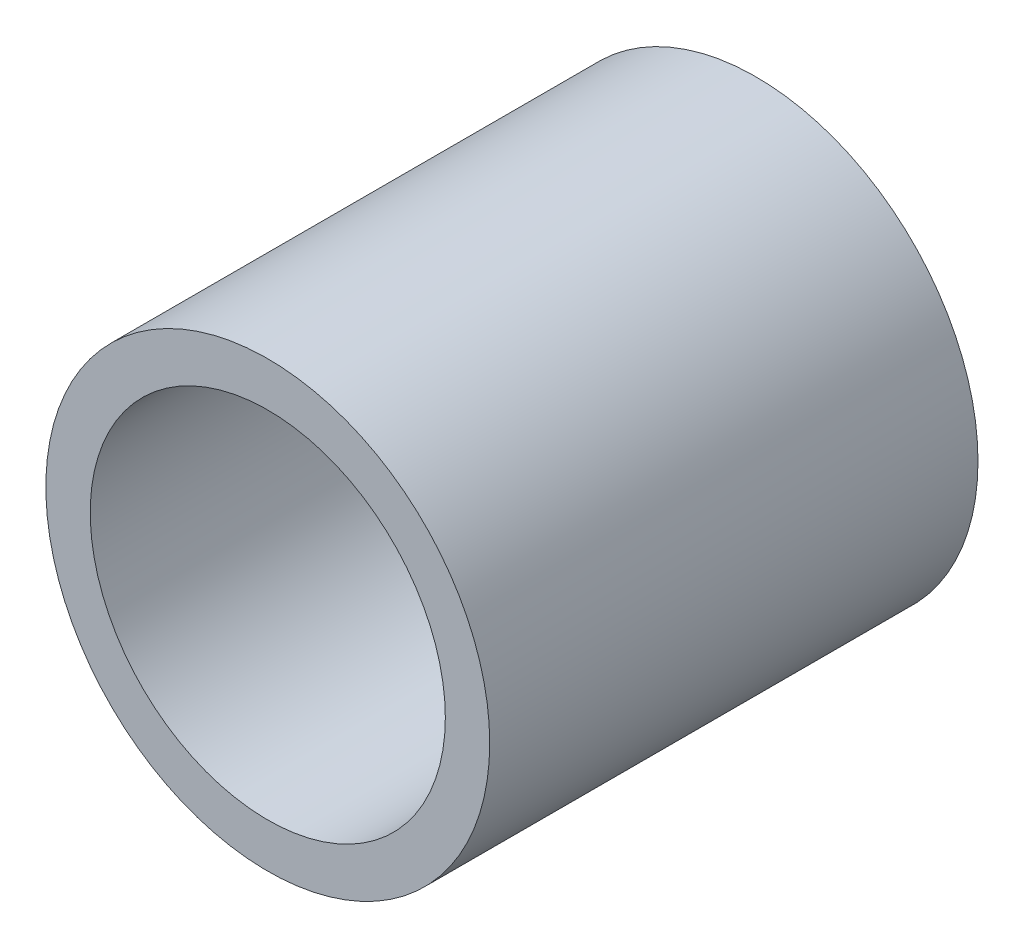
from build123d import *

# Parameters (mm, degrees)
SKETCH1_R           = 0.625
SKETCH1_R_2         = 0.5
BOSS_EXTRUDE1_DEPTH = 1.375


with BuildPart() as part:
    # Sketch1 → Boss-Extrude1 (new body)
    with BuildSketch(Plane.XY):
        Circle(SKETCH1_R)
        Circle(SKETCH1_R_2, mode=Mode.SUBTRACT)
    extrude(amount=BOSS_EXTRUDE1_DEPTH)


solid = part.part
